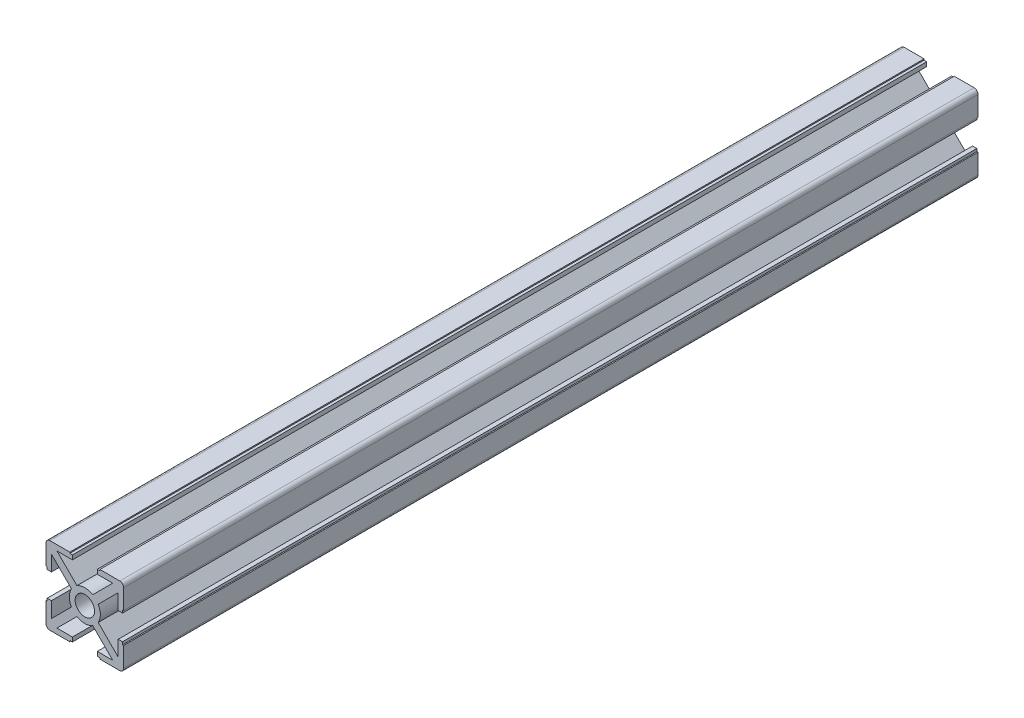
from build123d import *

# Parameters (mm, degrees)
SKETCH1_R           = 2.5
BOSS_EXTRUDE1_DEPTH = 220


with BuildPart() as part:
    # Sketch1 → Boss-Extrude1 (new body)
    with BuildSketch(Plane.XY):
        with BuildLine():
            Line((-9.707106781, -3.2), (-8.6, -3.2))
            Line((-8.6, -3.2), (-8.6, -7.185786438))
            Line((-8.6, -7.185786438), (-3.445719569, -2.031506006))
            ThreePointArc((-3.445719569, -2.031506006), (-4, 0), (-3.445719569, 2.031506006))
            Line((-3.445719569, 2.031506006), (-8.6, 7.185786438))
            Line((-8.6, 7.185786438), (-8.6, 3.2))
            Line((-8.6, 3.2), (-9.707106781, 3.2))
            Line((-9.707106781, 3.2), (-9.707106781, 3.877544562))
            Line((-9.707106781, 3.877544562), (-10, 3.877544562))
            Line((-10, 3.877544562), (-10, 9))
            ThreePointArc((-10, 9), (-9.707106781, 9.707106781), (-9, 10))
            Line((-9, 10), (-3.877544562, 10))
            Line((-3.877544562, 10), (-3.877544562, 9.707106781))
            Line((-3.877544562, 9.707106781), (-3.2, 9.707106781))
            Line((-3.2, 9.707106781), (-3.2, 8.6))
            Line((-3.2, 8.6), (-7.185786438, 8.6))
            Line((-7.185786438, 8.6), (-2.031506006, 3.445719569))
            ThreePointArc((-2.031506006, 3.445719569), (0, 4), (2.031506006, 3.445719569))
            Line((2.031506006, 3.445719569), (7.185786438, 8.6))
            Line((7.185786438, 8.6), (3.2, 8.6))
            Line((3.2, 8.6), (3.2, 9.707106781))
            Line((3.2, 9.707106781), (3.877544562, 9.707106781))
            Line((3.877544562, 9.707106781), (3.877544562, 10))
            Line((3.877544562, 10), (9, 10))
            ThreePointArc((9, 10), (9.707106781, 9.707106781), (10, 9))
            Line((10, 9), (10, 3.877544562))
            Line((10, 3.877544562), (9.707106781, 3.877544562))
            Line((9.707106781, 3.877544562), (9.707106781, 3.2))
            Line((9.707106781, 3.2), (8.6, 3.2))
            Line((8.6, 3.2), (8.6, 7.185786438))
            Line((8.6, 7.185786438), (3.445719569, 2.031506006))
            ThreePointArc((3.445719569, 2.031506006), (4, 0), (3.445719569, -2.031506006))
            Line((3.445719569, -2.031506006), (8.6, -7.185786438))
            Line((8.6, -7.185786438), (8.6, -3.2))
            Line((8.6, -3.2), (9.707106781, -3.2))
            Line((9.707106781, -3.2), (9.707106781, -3.877544562))
            Line((9.707106781, -3.877544562), (10, -3.877544562))
            Line((10, -3.877544562), (10, -9))
            ThreePointArc((10, -9), (9.707106781, -9.707106781), (9, -10))
            Line((9, -10), (3.877544562, -10))
            Line((3.877544562, -10), (3.877544562, -9.707106781))
            Line((3.877544562, -9.707106781), (3.2, -9.707106781))
            Line((3.2, -9.707106781), (3.2, -8.6))
            Line((3.2, -8.6), (7.185786438, -8.6))
            Line((7.185786438, -8.6), (2.031506006, -3.445719569))
            ThreePointArc((2.031506006, -3.445719569), (0, -4), (-2.031506006, -3.445719569))
            Line((-2.031506006, -3.445719569), (-7.185786438, -8.6))
            Line((-7.185786438, -8.6), (-3.2, -8.6))
            Line((-3.2, -8.6), (-3.2, -9.707106781))
            Line((-3.2, -9.707106781), (-3.877544562, -9.707106781))
            Line((-3.877544562, -9.707106781), (-3.877544562, -10))
            Line((-3.877544562, -10), (-9, -10))
            ThreePointArc((-9, -10), (-9.707106781, -9.707106781), (-10, -9))
            Line((-10, -9), (-10, -3.877544562))
            Line((-10, -3.877544562), (-9.707106781, -3.877544562))
            Line((-9.707106781, -3.877544562), (-9.707106781, -3.2))
        make_face()
        Circle(SKETCH1_R, mode=Mode.SUBTRACT)
    extrude(amount=BOSS_EXTRUDE1_DEPTH)


solid = part.part
